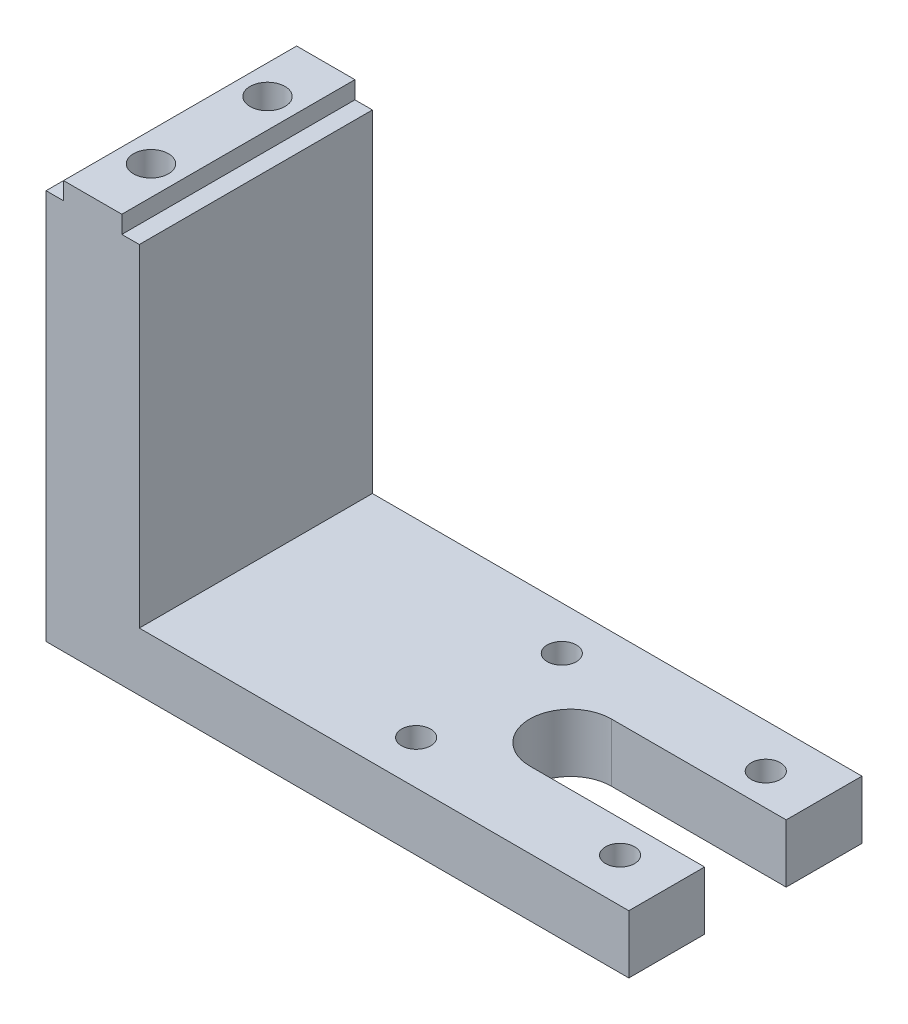
from build123d import *

# Parameters (mm, degrees)
EXTRUDE_1_DEPTH     = 20
SKETCH_4_R          = 3
CUT_EXTRUDE_1_DEPTH = 10
SKETCH_5_R          = 2.5
CUT_EXTRUDE_2_DEPTH = 11


with BuildPart() as part:
    # 草圖1 → 填料-伸長1 (new body, symmetric)
    with BuildSketch(Plane.XY):
        Polygon((0, 0), (84, 0), (84, -10), (-16, -10), (-16, 57), (-13, 57), (-13, 60), (-3, 60), (-3, 57), (0, 57), align=None)
    extrude(amount=EXTRUDE_1_DEPTH, both=True)

    # 草圖4 → 除料-伸長1 (cut)
    with BuildSketch(Plane(origin=(0, 60, 0), x_dir=(1, 0, 0), z_dir=(0, 1, 0))):
        with Locations((-8, 10)):
            Circle(SKETCH_4_R)
        with Locations((-8, -10)):
            Circle(SKETCH_4_R)
    extrude(amount=-CUT_EXTRUDE_1_DEPTH, mode=Mode.SUBTRACT)

    # 草圖5 → 除料-伸長2 (cut, through all)
    with BuildSketch(Plane(origin=(0, 0, 0), x_dir=(1, 0, 0), z_dir=(0, 1, 0))):
        with Locations((40, -12.5)):
            Circle(SKETCH_5_R)
        with Locations((40, 12.5)):
            Circle(SKETCH_5_R)
        with Locations((75, 12.5)):
            Circle(SKETCH_5_R)
        with Locations((75, -12.5)):
            Circle(SKETCH_5_R)
        with BuildLine():
            Line((84, 7), (54, 7))
            ThreePointArc((54, 7), (47, 0), (54, -7))
            Line((54, -7), (84, -7))
            Line((84, -7), (84, 7))
        make_face()
    extrude(amount=-CUT_EXTRUDE_2_DEPTH, mode=Mode.SUBTRACT)


solid = part.part
